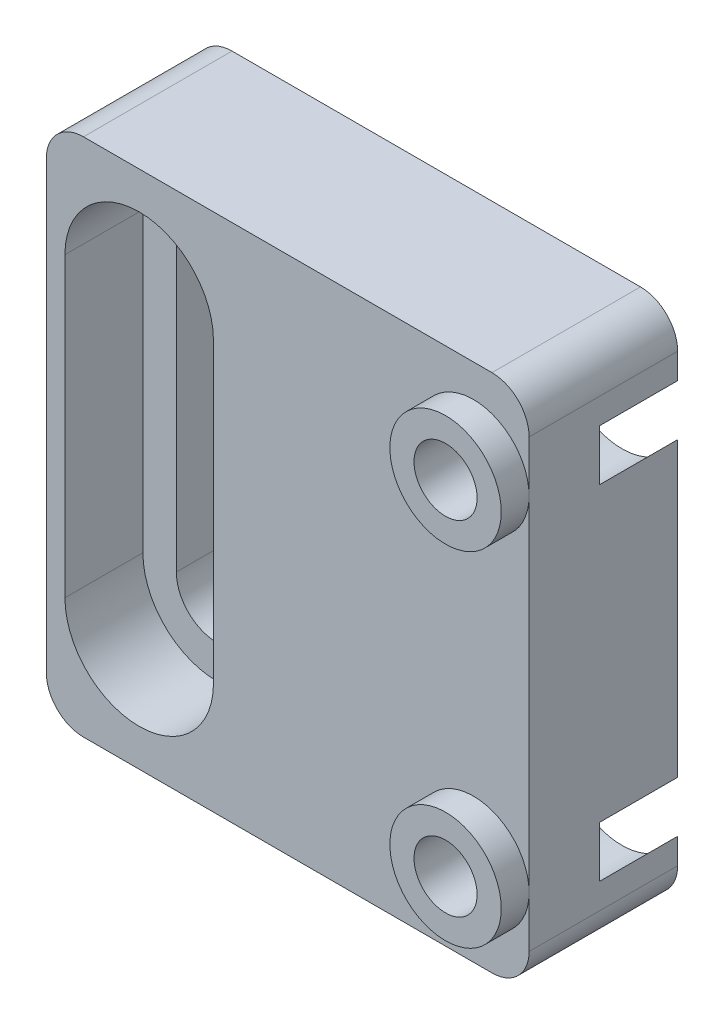
from build123d import *

# Parameters (mm, degrees)
ESQUISSE1_W             = 26
ESQUISSE1_H             = 28
BOSS_EXTRU_1_DEPTH      = 8
ENL_V_MAT_EXTRU_1_DEPTH = 9
ENL_V_MAT_EXTRU_2_DEPTH = 4.2
ESQUISSE4_R             = 1.7
ENL_V_MAT_EXTRU_3_DEPTH = 9
ESQUISSE5_R             = 3.3
ENL_V_MAT_EXTRU_6_DEPTH = 4.2
ESQUISSE6_R             = 1.7
BOSS_EXTRU_2_DEPTH      = 1
ESQUISSE7_R             = 3
ESQUISSE7_R_2           = 1.7
BOSS_EXTRU_3_DEPTH      = 1.5
FILLET1_R               = 2


with BuildPart() as part:
    # Esquisse1 → Boss.-Extru.1 (new body)
    with BuildSketch(Plane.XY):
        with Locations((5, 0)):
            Rectangle(ESQUISSE1_W, ESQUISSE1_H)
    extrude(amount=BOSS_EXTRU_1_DEPTH)

    # Esquisse2 → Enlèv. mat.-Extru.1 (cut, through all)
    with BuildSketch(Plane.XY.offset(8)):
        with BuildLine():
            Line((-0.8, 8), (-0.8, -8))
            ThreePointArc((-0.8, -8), (-3, -10.2), (-5.2, -8))
            Line((-5.2, -8), (-5.2, 8))
            ThreePointArc((-5.2, 8), (-3, 10.2), (-0.8, 8))
        make_face()
    extrude(amount=-ENL_V_MAT_EXTRU_1_DEPTH, mode=Mode.SUBTRACT)

    # Esquisse3 → Enlèv. mat.-Extru.2 (cut)
    with BuildSketch(Plane.XY.offset(8)):
        with BuildLine():
            Line((1, 8), (1, -8))
            ThreePointArc((1, -8), (-3, -12), (-7, -8))
            Line((-7, -8), (-7, 8))
            ThreePointArc((-7, 8), (-3, 12), (1, 8))
        make_face()
    extrude(amount=-ENL_V_MAT_EXTRU_2_DEPTH, mode=Mode.SUBTRACT)

    # Esquisse4 → Enlèv. mat.-Extru.3 (cut, through all)
    with BuildSketch(Plane.XY.offset(8)):
        with Locations((15, 9.25)):
            Circle(ESQUISSE4_R)
        with Locations((15, -9.25)):
            Circle(ESQUISSE4_R)
    extrude(amount=-ENL_V_MAT_EXTRU_3_DEPTH, mode=Mode.SUBTRACT)

    # Esquisse5 → Enlèv. mat.-Extru.6 (cut)
    with BuildSketch(Plane(origin=(0, 0, 0), x_dir=(-1, 0, 0), z_dir=(0, 0, -1))):
        with Locations((-15, 9.25)):
            Circle(ESQUISSE5_R)
        with Locations((-15, -9.25)):
            Circle(ESQUISSE5_R)
    extrude(amount=-ENL_V_MAT_EXTRU_6_DEPTH, mode=Mode.SUBTRACT)

    # Esquisse6 → Boss.-Extru.2 (add)
    with BuildSketch(Plane(origin=(0, 0, 4.2), x_dir=(-1, 0, 0), z_dir=(0, 0, -1))):
        with Locations((-15, 9.25)):
            Circle(ESQUISSE6_R)
        with Locations((-15, -9.25)):
            Circle(ESQUISSE6_R)
    extrude(amount=-BOSS_EXTRU_2_DEPTH)

    # Esquisse7 → Boss.-Extru.3 (add)
    with BuildSketch(Plane.XY.offset(8)):
        with Locations((15, -9.25)):
            Circle(ESQUISSE7_R)
        with Locations((15, -9.25)):
            Circle(ESQUISSE7_R_2, mode=Mode.SUBTRACT)
        with Locations((15, 9.25)):
            Circle(ESQUISSE7_R)
        with Locations((15, 9.25)):
            Circle(ESQUISSE7_R_2, mode=Mode.SUBTRACT)
    extrude(amount=BOSS_EXTRU_3_DEPTH)

    # Fillet1
    fillet1_edges = [part.edges().sort_by_distance(p)[0] for p in [
        (-8, 14, 4),
        (18, 14, 4),
        (18, -14, 4),
        (-8, -14, 4),
    ]]
    fillet(fillet1_edges, radius=FILLET1_R)


solid = part.part
